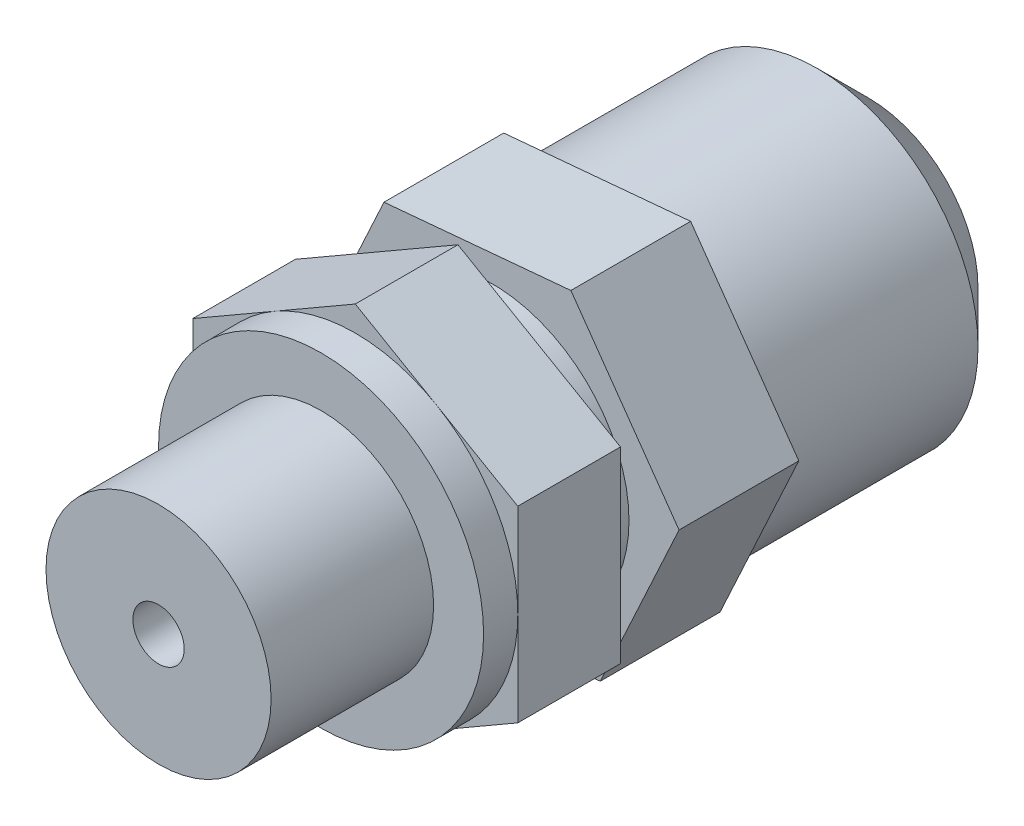
from build123d import *

# Parameters (mm, degrees)
BASE_EXTRUDE_DEPTH  = 6
SKETCH2_R           = 9.5
BOSS_EXTRUDE1_DEPTH = 2
SKETCH3_R           = 6.5785
BOSS_EXTRUDE2_DEPTH = 9.5
SKETCH4_R           = 1.5
CUT_EXTRUDE1_DEPTH  = 9.5
SKETCH5_R           = 8
BOSS_EXTRUDE3_DEPTH = 2
BOSS_EXTRUDE4_DEPTH = 7
SKETCH8_R           = 9.4
BOSS_EXTRUDE5_DEPTH = 15
CHAMFER1_SIZE       = 3


with BuildPart() as part:
    # Sketch1 → Base-Extrude (new body)
    with BuildSketch(Plane.XY):
        Polygon((0, 10.969655115), (-9.5, 5.484827557), (-9.5, -5.484827557), (0, -10.969655115), (9.5, -5.484827557), (9.5, 5.484827557), align=None)
    extrude(amount=BASE_EXTRUDE_DEPTH)

    # Sketch2 → Boss-Extrude1 (add)
    with BuildSketch(Plane.XY.offset(6)):
        Circle(SKETCH2_R)
    extrude(amount=BOSS_EXTRUDE1_DEPTH)

    # Sketch3 → Boss-Extrude2 (add)
    with BuildSketch(Plane.XY.offset(8)):
        Circle(SKETCH3_R)
    extrude(amount=BOSS_EXTRUDE2_DEPTH)

    # Sketch4 → Cut-Extrude1 (cut)
    with BuildSketch(Plane.XY.offset(17.5)):
        Circle(SKETCH4_R)
    extrude(amount=-CUT_EXTRUDE1_DEPTH, mode=Mode.SUBTRACT)

    # Sketch5 → Boss-Extrude3 (add)
    with BuildSketch(Plane(origin=(0, 0, 0), x_dir=(-1, 0, 0), z_dir=(0, 0, -1))):
        Circle(SKETCH5_R)
    extrude(amount=BOSS_EXTRUDE3_DEPTH)

    # Sketch7 → Boss-Extrude4 (add)
    with BuildSketch(Plane(origin=(0, 0, -2), x_dir=(-1, 0, 0), z_dir=(0, 0, -1))):
        Polygon((10.924605006, -0.99314591), (6.32239209, 8.964412507), (-4.602212916, 9.957558416), (-10.924605006, 0.99314591), (-6.32239209, -8.964412507), (4.602212916, -9.957558416), align=None)
    extrude(amount=BOSS_EXTRUDE4_DEPTH)

    # Sketch8 → Boss-Extrude5 (add)
    with BuildSketch(Plane(origin=(0, 0, -9), x_dir=(-1, 0, 0), z_dir=(0, 0, -1))):
        Circle(SKETCH8_R)
    extrude(amount=BOSS_EXTRUDE5_DEPTH)

    # Chamfer1
    chamfer1_edges = [part.edges().sort_by_distance(p)[0] for p in [
        (9.4, 0, -24),
    ]]
    chamfer(chamfer1_edges, length=CHAMFER1_SIZE)


solid = part.part
